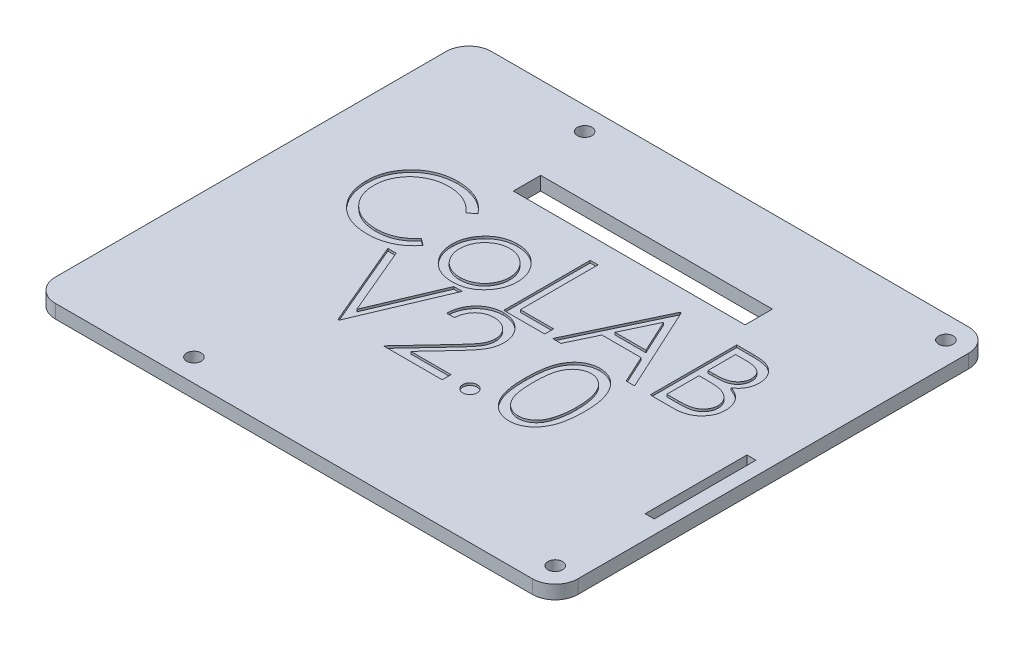
from build123d import *

# Parameters (mm, degrees)
BOSS_EXTRUDE1_DEPTH     = 3
CUT_EXTRUDE1_DEPTH      = 0.5
SKETCH3_R               = 1.6
CUT_EXTRUDE2_DEPTH      = 1
CUT_EXTRUDE2_DEPTH_BACK = 4.0000001
SKETCH5_W               = 2
SKETCH5_H               = 22.4
CUT_EXTRUDE3_DEPTH      = 1.0000001
CUT_EXTRUDE3_DEPTH_BACK = 4
SKETCH6_R               = 3.5
SKETCH6_R_2             = 1.45
BOSS_EXTRUDE2_DEPTH     = 5
SKETCH7_W               = 51
SKETCH7_H               = 6
CUT_EXTRUDE4_DEPTH      = 1.0000001
CUT_EXTRUDE4_DEPTH_BACK = 9


with BuildPart() as part:
    # Sketch1 → Boss-Extrude1 (new body)
    with BuildSketch(Plane(origin=(0, 0, 0), x_dir=(1, 0, 0), z_dir=(0, 1, 0))):
        with BuildLine():
            Line((5, 0), (110, 0))
            ThreePointArc((110, 0), (113.535533906, 1.464466094), (115, 5))
            Line((115, 5), (115, 91))
            ThreePointArc((115, 91), (113.535533906, 94.535533906), (110, 96))
            Line((110, 96), (5, 96))
            ThreePointArc((5, 96), (1.464466094, 94.535533906), (0, 91))
            Line((0, 91), (0, 5))
            ThreePointArc((0, 5), (1.464466094, 1.464466094), (5, 0))
        make_face()
    extrude(amount=BOSS_EXTRUDE1_DEPTH)

    # Sketch2 → Cut-Extrude1 (cut)
    with BuildSketch(Plane(origin=(0, 3, 0), x_dir=(1, 0, 0), z_dir=(0, 1, 0))):
        with BuildLine():
            Line((34.420192308, 63.554447115), (32.924278846, 62.409615385))
            add(Edge.make_bspline(
                [(32.924278846, 62.409615385), (32.817566797, 62.53679302), (32.605581408, 62.789433662), (32.26453632, 63.144196611), (31.909108806, 63.476566105), (31.539434732, 63.788125479), (31.148860096, 64.067979589), (30.74684632, 64.330712307), (30.326668389, 64.566212423), (29.745633947, 64.851760962), (28.985550659, 65.149736463), (28.028724463, 65.399581193), (27.02989977, 65.558627878), (26.348467121, 65.575853658), (26.001862981, 65.584615385)],
                knots=[0, 0, 0, 0, 0.00049794, 0.000989166, 0.001475147, 0.001957397, 0.002438287, 0.002915667, 0.003397525, 0.003882215, 0.004857325, 0.005840349, 0.006844209, 0.007883375, 0.007883375, 0.007883375, 0.007883375], degree=3))
            add(Edge.make_bspline(
                [(26.001862981, 65.584615385), (25.810909594, 65.582416674), (25.430775049, 65.57803966), (24.866631215, 65.520295707), (24.313021608, 65.439136121), (23.770306342, 65.318711147), (23.239176239, 65.166460178), (22.716159022, 64.984530425), (22.208827043, 64.759441939), (21.710162061, 64.51065841), (21.232392355, 64.229657604), (20.780335595, 63.923152074), (20.355640513, 63.594571707), (19.957971152, 63.24268497), (19.586920976, 62.869076586), (19.245178613, 62.469764955), (18.933926594, 62.046026696), (18.646995358, 61.603449435), (18.390023195, 61.143322312), (18.174867709, 60.663942286), (17.984339829, 60.173518525), (17.833576809, 59.666510064), (17.714244796, 59.146484438), (17.631907085, 58.612046007), (17.574819835, 58.064311265), (17.570464586, 57.693057721), (17.568269231, 57.505919471)],
                knots=[0, 0, 0, 0, 0.000572619, 0.001139924, 0.001699592, 0.002250514, 0.002806148, 0.003356514, 0.003910218, 0.00446999, 0.005027612, 0.005571644, 0.006107491, 0.006637367, 0.007163561, 0.007685922, 0.008212558, 0.008739692, 0.009267502, 0.009791769, 0.010314798, 0.010844798, 0.0113771, 0.011914141, 0.012466252, 0.013027427, 0.013027427, 0.013027427, 0.013027427], degree=3))
            add(Edge.make_bspline(
                [(17.568269231, 57.505919471), (17.575137131, 57.224353287), (17.588621343, 56.671535432), (17.708627276, 55.861798252), (17.890990702, 55.086078585), (18.164306913, 54.349225443), (18.50132346, 53.642152809), (18.927175931, 52.976824192), (19.420388799, 52.343185462), (19.987939567, 51.756211704), (20.61063408, 51.220015571), (21.278733428, 50.747844548), (21.990573622, 50.354244974), (22.738294995, 50.026715893), (23.527651415, 49.774947133), (24.357223411, 49.597705261), (25.2252067, 49.482087107), (25.818311576, 49.471018033), (26.12016226, 49.465384615)],
                knots=[0, 0, 0, 0, 0.000844222, 0.001657519, 0.002450727, 0.003230596, 0.004010586, 0.004796148, 0.005595401, 0.006415872, 0.007241219, 0.008057492, 0.008865515, 0.009677279, 0.010502758, 0.011346325, 0.012219621, 0.01312469, 0.01312469, 0.01312469, 0.01312469], degree=3))
            add(Edge.make_bspline(
                [(26.12016226, 49.465384615), (26.452735467, 49.474576402), (27.107319097, 49.492668038), (28.067265069, 49.645934808), (28.986214022, 49.894444332), (29.864215386, 50.242231595), (30.69879396, 50.694344091), (31.491255782, 51.242428252), (32.242269759, 51.891697606), (32.693870595, 52.387450061), (32.924278846, 52.640384615)],
                knots=[0, 0, 0, 0, 0.000997238, 0.001962804, 0.002907981, 0.00384834, 0.004789132, 0.005749229, 0.006733947, 0.007759692, 0.007759692, 0.007759692, 0.007759692], degree=3))
            Line((32.924278846, 52.640384615), (34.420192308, 51.507001202))
            add(Edge.make_bspline(
                [(34.420192308, 51.507001202), (34.299806595, 51.351670485), (34.059611811, 51.041753077), (33.670676033, 50.604845628), (33.260952457, 50.193887949), (32.827397807, 49.812193325), (32.374999542, 49.452124019), (31.895634527, 49.123909766), (31.395604507, 48.822969382), (30.876603701, 48.547414264), (30.339183537, 48.302936105), (29.78398797, 48.093637741), (29.213410123, 47.913343699), (28.627423913, 47.7650153), (28.024813865, 47.64923983), (27.40775457, 47.571844171), (26.774914249, 47.518820322), (26.3479688, 47.513987523), (26.131610577, 47.511538462)],
                knots=[0, 0, 0, 0, 0.000589425, 0.001176026, 0.001753482, 0.00232931, 0.002908013, 0.003487018, 0.004070795, 0.004658029, 0.005248935, 0.005840739, 0.006436956, 0.007043188, 0.007653157, 0.008276538, 0.008908147, 0.009557065, 0.009557065, 0.009557065, 0.009557065], degree=3))
            add(Edge.make_bspline(
                [(26.131610577, 47.511538462), (25.926721475, 47.51296445), (25.521578647, 47.515784164), (24.923415442, 47.561461533), (24.341086438, 47.623780815), (23.776255974, 47.717616386), (23.225841739, 47.828347722), (22.694833415, 47.976781276), (22.17800577, 48.143056026), (21.67743523, 48.338481739), (21.192696006, 48.559005533), (20.725351547, 48.808242446), (20.275616794, 49.084096595), (19.839070146, 49.380487438), (19.422160441, 49.706935324), (19.021274824, 50.058906577), (18.634165346, 50.435214893), (18.394665018, 50.706567737), (18.274248798, 50.842998798)],
                knots=[0, 0, 0, 0, 0.0006145, 0.001215097, 0.001798762, 0.002370923, 0.002932241, 0.003482144, 0.004023991, 0.004560449, 0.005093244, 0.005620764, 0.006148271, 0.006675391, 0.00720287, 0.00773561, 0.008275316, 0.008821059, 0.008821059, 0.008821059, 0.008821059], degree=3))
            add(Edge.make_bspline(
                [(18.274248798, 50.842998798), (18.081377653, 51.079987269), (17.697963872, 51.551103079), (17.207422651, 52.314659634), (16.787519529, 53.111865171), (16.448016303, 53.946907926), (16.182607713, 54.817914134), (15.998741494, 55.725322862), (15.879262047, 56.668286662), (15.865598904, 57.309655469), (15.858653846, 57.635667067)],
                knots=[0, 0, 0, 0, 0.000916064, 0.001821069, 0.002717204, 0.003615773, 0.004521164, 0.005444709, 0.006390426, 0.007368094, 0.007368094, 0.007368094, 0.007368094], degree=3))
            add(Edge.make_bspline(
                [(15.858653846, 57.635667067), (15.867118543, 57.978324607), (15.883772304, 58.652481925), (16.025263705, 59.641851585), (16.252877439, 60.589732771), (16.576166218, 61.494356009), (16.986042487, 62.360479391), (17.492373057, 63.181486521), (18.089275645, 63.962627959), (18.772068835, 64.692051105), (19.520828189, 65.359015296), (20.322663447, 65.945789062), (21.176005187, 66.434108685), (22.071452351, 66.842302083), (23.015710132, 67.156052661), (24.006763899, 67.375689291), (25.04275142, 67.512398167), (25.749574052, 67.52968037), (26.108713942, 67.538461538)],
                knots=[0, 0, 0, 0, 0.001027553, 0.002021647, 0.002991636, 0.003947584, 0.004898354, 0.00586111, 0.006835779, 0.007842891, 0.008853835, 0.009840024, 0.01081793, 0.011798246, 0.012787788, 0.013796915, 0.014839669, 0.015916785, 0.015916785, 0.015916785, 0.015916785], degree=3))
            add(Edge.make_bspline(
                [(26.108713942, 67.538461538), (26.327595568, 67.535837329), (26.760849703, 67.530642971), (27.401760569, 67.479990969), (28.025742377, 67.395552627), (28.633225008, 67.280620875), (29.227163819, 67.137978168), (29.803019415, 66.952157402), (30.36417084, 66.739687138), (30.907079011, 66.494984631), (31.429139091, 66.220301367), (31.930188482, 65.918682045), (32.406247213, 65.590500589), (32.860665088, 65.238548163), (33.285840466, 64.855378861), (33.693845084, 64.451531946), (34.070823238, 64.015374989), (34.303522771, 63.708370992), (34.420192308, 63.554447115)],
                knots=[0, 0, 0, 0, 0.000656548, 0.00129957, 0.001927235, 0.002544702, 0.003153715, 0.00375836, 0.004358654, 0.004953036, 0.005543646, 0.006127422, 0.006706428, 0.007277417, 0.007850392, 0.008422452, 0.008998633, 0.009577991, 0.009577991, 0.009577991, 0.009577991], degree=3))
        make_face()
        with BuildLine():
            add(Edge.make_bspline(
                [(44.563401442, 62.165384615), (44.824611084, 62.159822608), (45.336779356, 62.148916871), (46.086847992, 62.032358272), (46.802829375, 61.854119046), (47.48746565, 61.607712401), (48.131988629, 61.277429213), (48.745786401, 60.883315785), (49.32717612, 60.416413383), (49.675644323, 60.055235897), (49.852524038, 59.871905048)],
                knots=[0, 0, 0, 0, 0.000783055, 0.00153538, 0.002271186, 0.002994326, 0.003712818, 0.004438972, 0.005179778, 0.005943429, 0.005943429, 0.005943429, 0.005943429], degree=3))
            add(Edge.make_bspline(
                [(49.852524038, 59.871905048), (50.004825817, 59.696568925), (50.306481915, 59.349289917), (50.69328247, 58.786195795), (51.026502676, 58.203047533), (51.293545364, 57.59210137), (51.504102421, 56.958690659), (51.653594282, 56.300638284), (51.742513886, 55.619397509), (51.75450432, 55.156733762), (51.760576923, 54.922415865)],
                knots=[0, 0, 0, 0, 0.000696259, 0.001379043, 0.002045498, 0.002708457, 0.003375796, 0.004045107, 0.00473002, 0.005432847, 0.005432847, 0.005432847, 0.005432847], degree=3))
            add(Edge.make_bspline(
                [(51.760576923, 54.922415865), (51.755235644, 54.686739837), (51.744681028, 54.221033014), (51.644839345, 53.535127609), (51.48954872, 52.870038646), (51.267306858, 52.228550613), (50.982329149, 51.608702652), (50.634581264, 51.013202105), (50.221622891, 50.440874065), (49.753515423, 49.896578346), (49.23616164, 49.394930805), (48.674915175, 48.95771551), (48.080805363, 48.583129784), (47.445932254, 48.281397293), (46.776093505, 48.043491639), (46.06984432, 47.876395835), (45.328281865, 47.775367242), (44.821947989, 47.762393793), (44.563401442, 47.755769231)],
                knots=[0, 0, 0, 0, 0.000706639, 0.001396352, 0.002074825, 0.002753062, 0.003429246, 0.004118441, 0.004818465, 0.005543646, 0.006269639, 0.006976516, 0.007674289, 0.008372397, 0.009080888, 0.009802849, 0.01054601, 0.011321441, 0.011321441, 0.011321441, 0.011321441], degree=3))
            add(Edge.make_bspline(
                [(44.563401442, 47.755769231), (44.303588183, 47.762416027), (43.79473079, 47.775434114), (43.050550802, 47.876003324), (42.343035876, 48.04341463), (41.672320219, 48.282179126), (41.034717552, 48.583139428), (40.437165333, 48.956583053), (39.875462935, 49.395060469), (39.357999706, 49.896543212), (38.889921583, 50.440883117), (38.476955637, 51.013199756), (38.129209719, 51.608703264), (37.844231495, 52.228550449), (37.62198977, 52.870038689), (37.466699109, 53.535127597), (37.366857435, 54.221033017), (37.356302818, 54.686739838), (37.350961538, 54.922415865)],
                knots=[0, 0, 0, 0, 0.000779243, 0.001526186, 0.002248147, 0.002956639, 0.00365819, 0.004359201, 0.005066078, 0.005792071, 0.006517252, 0.007217276, 0.007906471, 0.008582655, 0.009260891, 0.009939365, 0.010629078, 0.011335717, 0.011335717, 0.011335717, 0.011335717], degree=3))
            add(Edge.make_bspline(
                [(37.350961538, 54.922415865), (37.357075556, 55.155460208), (37.369180261, 55.616847955), (37.45801046, 56.2968081), (37.606919175, 56.953746746), (37.817728633, 57.584712551), (38.087232743, 58.192981424), (38.41577061, 58.777570576), (38.806516767, 59.338118461), (39.106973103, 59.68494864), (39.259014423, 59.860456731)],
                knots=[0, 0, 0, 0, 0.000699014, 0.001383928, 0.002053239, 0.002716956, 0.003376425, 0.004046203, 0.004725856, 0.005422115, 0.005422115, 0.005422115, 0.005422115], degree=3))
            add(Edge.make_bspline(
                [(39.259014423, 59.860456731), (39.435627469, 60.045377472), (39.782968099, 60.409056647), (40.367251888, 60.874597956), (40.979539686, 61.276912587), (41.631185356, 61.600633131), (42.315259197, 61.855568492), (43.034909645, 62.032817938), (43.787523522, 62.148496913), (44.302198031, 62.159699281), (44.563401442, 62.165384615)],
                knots=[0, 0, 0, 0, 0.000766344, 0.00150715, 0.002235377, 0.002960688, 0.003685145, 0.004420951, 0.005180826, 0.005963881, 0.005963881, 0.005963881, 0.005963881], degree=3))
        make_face()
        with BuildLine():
            add(Edge.make_bspline(
                [(44.555769231, 60.455769231), (44.371051661, 60.450519096), (44.006384975, 60.440154358), (43.469612663, 60.361320534), (42.952866969, 60.236420547), (42.455167517, 60.058961327), (41.978192678, 59.829823034), (41.521485788, 59.548381817), (41.083703508, 59.218365296), (40.673409706, 58.840289898), (40.296860264, 58.427291371), (39.967687277, 57.987245303), (39.68778777, 57.527289333), (39.454614905, 57.046945155), (39.280948638, 56.541345016), (39.154821187, 56.016214723), (39.076061735, 55.470484385), (39.065794446, 55.0994937), (39.060576923, 54.910967548)],
                knots=[0, 0, 0, 0, 0.00055398, 0.001093659, 0.001624001, 0.002146641, 0.00267576, 0.003208513, 0.003753455, 0.004317942, 0.004879857, 0.00542785, 0.00596386, 0.006492979, 0.007026416, 0.007564175, 0.008111411, 0.008676826, 0.008676826, 0.008676826, 0.008676826], degree=3))
            add(Edge.make_bspline(
                [(39.060576923, 54.910967548), (39.069322635, 54.667388657), (39.086681237, 54.183930107), (39.227843023, 53.471943854), (39.463988347, 52.788419773), (39.782870541, 52.137364872), (40.182410102, 51.534991473), (40.653146851, 50.99793668), (41.190028649, 50.534282477), (41.7866556, 50.149576732), (42.430841244, 49.843907205), (43.112593506, 49.627287066), (43.823652141, 49.48647114), (44.309594406, 49.472474972), (44.555769231, 49.465384615)],
                knots=[0, 0, 0, 0, 0.000730313, 0.001449535, 0.002167582, 0.002894618, 0.003618562, 0.004329721, 0.005030483, 0.005739673, 0.006453204, 0.007162815, 0.007881317, 0.008619021, 0.008619021, 0.008619021, 0.008619021], degree=3))
            add(Edge.make_bspline(
                [(44.555769231, 49.465384615), (44.801929896, 49.472516284), (45.287844211, 49.486593999), (45.997914874, 49.62657786), (46.677803778, 49.844856357), (47.32132033, 50.149232956), (47.9176757, 50.535743385), (48.458418775, 50.995318523), (48.925136215, 51.536413914), (49.32428055, 52.138162749), (49.648384964, 52.787410437), (49.883424963, 53.472070008), (50.024926109, 54.183897979), (50.042238905, 54.667377893), (50.050961538, 54.910967548)],
                knots=[0, 0, 0, 0, 0.000737704, 0.001456207, 0.002162186, 0.002875716, 0.003584906, 0.004288562, 0.004997207, 0.005721152, 0.006449878, 0.007167925, 0.007887147, 0.00861746, 0.00861746, 0.00861746, 0.00861746], degree=3))
            add(Edge.make_bspline(
                [(50.050961538, 54.910967548), (50.045745812, 55.099494826), (50.035482057, 55.470487729), (49.956696894, 56.016201941), (49.8306646, 56.541391917), (49.656647654, 57.046772106), (49.42448795, 57.528533022), (49.139190834, 57.985894822), (48.811361967, 58.428815737), (48.43026878, 58.838954839), (48.020403252, 59.218512681), (47.582443544, 59.548509786), (47.126413875, 59.828586128), (46.650824732, 60.060921237), (46.153061471, 60.234806047), (45.637039811, 60.362041712), (45.102557717, 60.439821211), (44.739197782, 60.450419224), (44.555769231, 60.455769231)],
                knots=[0, 0, 0, 0, 0.000565415, 0.00111265, 0.00165041, 0.002183846, 0.002712966, 0.003250969, 0.003798962, 0.004363449, 0.004927936, 0.005472878, 0.006005632, 0.006531314, 0.007057549, 0.007584185, 0.008123864, 0.008674032, 0.008674032, 0.008674032, 0.008674032], degree=3))
        make_face(mode=Mode.SUBTRACT)
        Polygon((55.668269231, 67.05), (57.377884615, 67.05), (57.377884615, 49.953846154), (64.704807692, 49.953846154), (64.704807692, 48), (55.668269231, 48), align=None)
        Polygon((75.695192308, 67.05), (84.4875, 48), (82.62905649, 48), (79.812770433, 54.105769231), (71.176923077, 54.105769231), (68.280498798, 48), (66.414423077, 48), (75.450961538, 67.05), align=None)
        Polygon((75.553996394, 63.336929087), (72.104236779, 56.059615385), (78.912169471, 56.059615385), align=None, mode=Mode.SUBTRACT)
        with BuildLine():
            Line((87.906730769, 67.05), (91.623617788, 67.05))
            add(Edge.make_bspline(
                [(91.623617788, 67.05), (91.80556422, 67.049043416), (92.158221686, 67.047189317), (92.671044648, 67.018433989), (93.151370317, 66.979225443), (93.599337993, 66.917013082), (94.014740673, 66.841946409), (94.398830241, 66.75104081), (94.750385322, 66.642038813), (95.17009893, 66.468704053), (95.648638527, 66.211130809), (96.166789778, 65.830519618), (96.609861424, 65.36497864), (96.991875522, 64.83983733), (97.295593045, 64.262155487), (97.515317363, 63.645701902), (97.654425227, 62.99842785), (97.668731419, 62.554055696), (97.675961538, 62.329477163)],
                knots=[0, 0, 0, 0, 0.000545756, 0.001057812, 0.00154047, 0.00199111, 0.00241401, 0.002806457, 0.003174568, 0.003516849, 0.004167392, 0.004800106, 0.005437019, 0.006087371, 0.006742853, 0.007387425, 0.008046032, 0.008718977, 0.008718977, 0.008718977, 0.008718977], degree=3))
            add(Edge.make_bspline(
                [(97.675961538, 62.329477163), (97.670011307, 62.119096825), (97.65831854, 61.705679619), (97.546507236, 61.101010253), (97.371461312, 60.525421476), (97.128137027, 59.981013921), (96.811896162, 59.480088113), (96.43711017, 59.018603136), (95.984935003, 58.616098097), (95.646153939, 58.391074585), (95.47406851, 58.276772837)],
                knots=[0, 0, 0, 0, 0.000630593, 0.001239176, 0.001837903, 0.002432285, 0.003022056, 0.003610343, 0.004210261, 0.004829576, 0.004829576, 0.004829576, 0.004829576], degree=3))
            add(Edge.make_bspline(
                [(95.47406851, 58.276772837), (95.690478837, 58.193687628), (96.104525402, 58.034725042), (96.674316412, 57.753680588), (97.165234069, 57.447998245), (97.581052821, 57.114177746), (97.936676342, 56.754356933), (98.247207353, 56.363259811), (98.512173118, 55.935784572), (98.739210602, 55.476388187), (98.916368831, 54.989761552), (99.049043396, 54.480469185), (99.125066227, 53.95033732), (99.135884674, 53.589555469), (99.141346154, 53.407421875)],
                knots=[0, 0, 0, 0, 0.00069517, 0.001330033, 0.001902818, 0.002426682, 0.002925892, 0.003417578, 0.003921593, 0.004431882, 0.004952231, 0.005472399, 0.0060083, 0.006554657, 0.006554657, 0.006554657, 0.006554657], degree=3))
            add(Edge.make_bspline(
                [(99.141346154, 53.407421875), (99.13602932, 53.221456471), (99.125568302, 52.855564329), (99.048388741, 52.318054239), (98.917710602, 51.804384887), (98.737709076, 51.311233821), (98.502782764, 50.839555089), (98.216880558, 50.388814324), (97.875985905, 49.963540324), (97.494643718, 49.559007461), (97.063231183, 49.195273362), (96.597781146, 48.871337873), (96.09243189, 48.604931449), (95.55548318, 48.381142817), (94.980911688, 48.210197923), (94.371297497, 48.090604342), (93.727166368, 48.010022641), (93.285153294, 48.003397568), (93.058473558, 48)],
                knots=[0, 0, 0, 0, 0.000557791, 0.00109747, 0.001625032, 0.002145382, 0.002669315, 0.003202874, 0.00374343, 0.00430216, 0.004867987, 0.005433235, 0.006000039, 0.006578327, 0.007175946, 0.007794874, 0.008440506, 0.009120159, 0.009120159, 0.009120159, 0.009120159], degree=3))
            Line((93.058473558, 48), (87.906730769, 48))
            Line((87.906730769, 48), (87.906730769, 67.05))
        make_face()
        with BuildLine():
            Line((89.616346154, 65.096153846), (89.616346154, 58.990384615))
            Line((89.616346154, 58.990384615), (90.76499399, 58.990384615))
            add(Edge.make_bspline(
                [(90.76499399, 58.990384615), (90.932899577, 58.992561339), (91.257327386, 58.996767213), (91.727154252, 59.00881507), (92.163263279, 59.042550135), (92.564901685, 59.076275504), (92.931436987, 59.131110046), (93.262057148, 59.196381458), (93.56195094, 59.265412698), (93.907787609, 59.382812334), (94.300070371, 59.556317966), (94.718261981, 59.825586103), (95.086931023, 60.146302939), (95.398247144, 60.516368031), (95.653035291, 60.923853986), (95.830002798, 61.362259149), (95.950003016, 61.820657296), (95.960842637, 62.135353787), (95.966346154, 62.295132212)],
                knots=[0, 0, 0, 0, 0.000503784, 0.000973413, 0.001409519, 0.001815822, 0.002182268, 0.002520548, 0.002826908, 0.003104462, 0.003615151, 0.004109495, 0.004590899, 0.005075605, 0.005555358, 0.006025916, 0.006489616, 0.006967864, 0.006967864, 0.006967864, 0.006967864], degree=3))
            add(Edge.make_bspline(
                [(95.966346154, 62.295132212), (95.96348223, 62.400863911), (95.957864331, 62.608268185), (95.911854213, 62.910615384), (95.833653558, 63.194970665), (95.733209476, 63.465230894), (95.592845327, 63.712945393), (95.427581334, 63.946679073), (95.227906363, 64.158472175), (95.000627275, 64.356426159), (94.7393232, 64.531928517), (94.444150026, 64.685638957), (94.11111424, 64.809413755), (93.745828558, 64.917814528), (93.342670211, 64.993950813), (92.90629157, 65.057378537), (92.433118314, 65.089669604), (92.105757113, 65.093944222), (91.936538462, 65.096153846)],
                knots=[0, 0, 0, 0, 0.000317104, 0.000622035, 0.000914559, 0.001200868, 0.001484418, 0.001766113, 0.002057739, 0.002355347, 0.002668639, 0.002999762, 0.003351279, 0.00373289, 0.004141516, 0.004580816, 0.005055258, 0.005562929, 0.005562929, 0.005562929, 0.005562929], degree=3))
            Line((91.936538462, 65.096153846), (89.616346154, 65.096153846))
        make_face(mode=Mode.SUBTRACT)
        with BuildLine():
            Line((89.616346154, 57.036538462), (89.616346154, 49.953846154))
            Line((89.616346154, 49.953846154), (92.051021635, 49.953846154))
            add(Edge.make_bspline(
                [(92.051021635, 49.953846154), (92.225296074, 49.955934836), (92.561187082, 49.959960496), (93.046152348, 49.973102571), (93.495640385, 50.002996243), (93.907600095, 50.050054368), (94.286479844, 50.101099927), (94.627734485, 50.169741327), (94.934130295, 50.248384955), (95.289409027, 50.369946664), (95.689478122, 50.558794599), (96.120611498, 50.84353346), (96.503931342, 51.182750321), (96.829442825, 51.575348582), (97.096213519, 52.00223909), (97.290281068, 52.454787352), (97.409974159, 52.925515723), (97.424463967, 53.246463115), (97.431730769, 53.407421875)],
                knots=[0, 0, 0, 0, 0.000522862, 0.001007748, 0.001455275, 0.001873744, 0.002251519, 0.00260177, 0.002917401, 0.003199793, 0.003727272, 0.004239541, 0.004745013, 0.005257068, 0.005764323, 0.006249869, 0.006729304, 0.007211645, 0.007211645, 0.007211645, 0.007211645], degree=3))
            add(Edge.make_bspline(
                [(97.431730769, 53.407421875), (97.430227973, 53.508078486), (97.42724662, 53.707768106), (97.382285273, 54.001224208), (97.316895496, 54.285482176), (97.23236012, 54.561313877), (97.109245592, 54.823732397), (96.96551854, 55.077927757), (96.797000054, 55.324235981), (96.534413951, 55.635634103), (96.152477864, 55.994410988), (95.609788129, 56.345679393), (94.992718907, 56.628968171), (94.54516641, 56.749252464), (94.313972356, 56.811388221)],
                knots=[0, 0, 0, 0, 0.00030169, 0.000598513, 0.000888261, 0.001176699, 0.001461887, 0.001755827, 0.002052208, 0.00235563, 0.002976636, 0.003615922, 0.004287047, 0.005004191, 0.005004191, 0.005004191, 0.005004191], degree=3))
            add(Edge.make_bspline(
                [(94.313972356, 56.811388221), (94.22128542, 56.83019375), (94.020321024, 56.870968014), (93.692619765, 56.914008514), (93.31850025, 56.952353768), (92.89709859, 56.980717355), (92.427881626, 57.010035542), (91.909847254, 57.021437354), (91.345111013, 57.03504047), (90.953266815, 57.036026358), (90.749729567, 57.036538462)],
                knots=[0, 0, 0, 0, 0.000283652, 0.000615017, 0.000990937, 0.001411818, 0.001881958, 0.002401173, 0.002966073, 0.003576662, 0.003576662, 0.003576662, 0.003576662], degree=3))
            Line((90.749729567, 57.036538462), (89.616346154, 57.036538462))
        make_face(mode=Mode.SUBTRACT)
        Polygon((31.123076923, 47.05), (32.954807692, 47.05), (39.304807692, 32.037439904), (45.654807692, 47.05), (47.486538462, 47.05), (39.426923077, 28), (39.182692308, 28), align=None)
        with BuildLine():
            Line((51.638461538, 41.188461538), (49.928846154, 41.188461538))
            add(Edge.make_bspline(
                [(49.928846154, 41.188461538), (49.939988515, 41.415270228), (49.961871816, 41.860716457), (50.064351505, 42.510179433), (50.210986851, 43.130963409), (50.418313194, 43.718083941), (50.675794505, 44.276732306), (50.98456794, 44.804689534), (51.350294469, 45.299941576), (51.765076836, 45.75789728), (52.215574714, 46.178018201), (52.701654185, 46.540813165), (53.212439262, 46.847342205), (53.746380276, 47.103598679), (54.309501344, 47.295948411), (54.896692327, 47.43866905), (55.510533055, 47.524537446), (55.928762318, 47.533767365), (56.141466346, 47.538461538)],
                knots=[0, 0, 0, 0, 0.000680809, 0.00133709, 0.001969252, 0.002592014, 0.003201565, 0.003812201, 0.004423565, 0.00504504, 0.005663449, 0.006268684, 0.006860967, 0.007448164, 0.008041934, 0.008642628, 0.00925895, 0.009896799, 0.009896799, 0.009896799, 0.009896799], degree=3))
            add(Edge.make_bspline(
                [(56.141466346, 47.538461538), (56.350352721, 47.533571368), (56.760806985, 47.523962359), (57.359858807, 47.441443042), (57.930146652, 47.312199179), (58.470555782, 47.130868128), (58.976774505, 46.887112887), (59.452605647, 46.59430057), (59.90371406, 46.255646916), (60.309788125, 45.856936874), (60.682667814, 45.431292467), (61.004352945, 44.976879735), (61.279833163, 44.507546051), (61.509454678, 44.019712554), (61.678488806, 43.508785956), (61.806821624, 42.982204753), (61.879360833, 42.434518281), (61.890493781, 42.063824029), (61.896153846, 41.875360577)],
                knots=[0, 0, 0, 0, 0.000626411, 0.001230876, 0.001810371, 0.002378766, 0.002936923, 0.003491927, 0.004052907, 0.004625069, 0.005195867, 0.00574861, 0.006292495, 0.006826886, 0.007362692, 0.007904163, 0.008450879, 0.009016294, 0.009016294, 0.009016294, 0.009016294], degree=3))
            add(Edge.make_bspline(
                [(61.896153846, 41.875360577), (61.886937658, 41.610033077), (61.868667014, 41.0840342), (61.712378764, 40.31106759), (61.468285611, 39.562166266), (61.174385711, 38.95943895), (60.87789998, 38.473753792), (60.610723689, 38.073874126), (60.297950932, 37.643314363), (59.935029393, 37.183516283), (59.529466474, 36.690878357), (59.0775887, 36.165698185), (58.576173747, 35.613401838), (58.224246765, 35.23618135), (58.041887019, 35.040715144)],
                knots=[0, 0, 0, 0, 0.000795299, 0.001576641, 0.002356211, 0.003153266, 0.003581282, 0.004062853, 0.004595648, 0.00517735, 0.005819874, 0.006509872, 0.007255587, 0.008057559, 0.008057559, 0.008057559, 0.008057559], degree=3))
            Line((58.041887019, 35.040715144), (53.275570913, 29.953846154))
            Line((53.275570913, 29.953846154), (62.140384615, 29.953846154))
            Line((62.140384615, 29.953846154), (62.140384615, 28))
            Line((62.140384615, 28), (49.196153846, 28))
            Line((49.196153846, 28), (56.584134615, 35.884074519))
            add(Edge.make_bspline(
                [(56.584134615, 35.884074519), (56.764009542, 36.071843873), (57.109512464, 36.432510375), (57.598186204, 36.959068486), (58.037092697, 37.447562415), (58.429073078, 37.8970692), (58.765624014, 38.314163877), (59.064285734, 38.685337906), (59.303584165, 39.026901414), (59.563292247, 39.422818184), (59.814828346, 39.906210939), (60.030977026, 40.496944305), (60.162774987, 41.10505978), (60.178585592, 41.516006582), (60.186538462, 41.722716346)],
                knots=[0, 0, 0, 0, 0.000780065, 0.001498345, 0.002154992, 0.002750207, 0.003287207, 0.003762814, 0.004178927, 0.004537763, 0.005182945, 0.005808274, 0.006420494, 0.007040127, 0.007040127, 0.007040127, 0.007040127], degree=3))
            add(Edge.make_bspline(
                [(60.186538462, 41.722716346), (60.183078207, 41.852699386), (60.17625871, 42.108870997), (60.116073242, 42.484459486), (60.025120345, 42.846762258), (59.894789726, 43.196893742), (59.722758755, 43.531333648), (59.513353644, 43.850489076), (59.27174487, 44.159039015), (58.992247247, 44.448344823), (58.685207404, 44.71330967), (58.360844417, 44.948027907), (58.017671706, 45.144183638), (57.657136184, 45.304984673), (57.280242986, 45.431124962), (56.886263159, 45.518529516), (56.476285299, 45.573407036), (56.19634013, 45.580832028), (56.053695913, 45.584615385)],
                knots=[0, 0, 0, 0, 0.00038971, 0.000768044, 0.001138265, 0.001508978, 0.001886155, 0.002264027, 0.002652614, 0.003060152, 0.003468689, 0.003867942, 0.004259386, 0.004652278, 0.005050509, 0.005449524, 0.005861328, 0.006289158, 0.006289158, 0.006289158, 0.006289158], degree=3))
            add(Edge.make_bspline(
                [(56.053695913, 45.584615385), (55.904720381, 45.580723566), (55.612157033, 45.573080677), (55.182612011, 45.51961732), (54.772842279, 45.427383532), (54.381817064, 45.301236204), (54.008874747, 45.140897531), (53.655829022, 44.941189607), (53.323472439, 44.702882308), (53.011180219, 44.432695852), (52.723449133, 44.131882194), (52.470645423, 43.796547966), (52.249752431, 43.432815891), (52.057025032, 43.041667409), (51.900511919, 42.619553263), (51.7809152, 42.167971898), (51.686281077, 41.688884094), (51.654666129, 41.35803956), (51.638461538, 41.188461538)],
                knots=[0, 0, 0, 0, 0.000446892, 0.000877622, 0.001296091, 0.001705198, 0.002108569, 0.002511851, 0.002919531, 0.003333451, 0.003749144, 0.004165869, 0.004590624, 0.005024118, 0.0054721, 0.005938665, 0.006424391, 0.006935151, 0.006935151, 0.006935151, 0.006935151], degree=3))
        make_face()
        with BuildLine():
            add(Edge.make_bspline(
                [(66.902884615, 30.930769231), (67.008967056, 30.924465495), (67.216929279, 30.912107758), (67.517587963, 30.827326148), (67.789701754, 30.67678401), (68.0320844, 30.476145174), (68.231872508, 30.232873064), (68.387779625, 29.962929618), (68.471822701, 29.659753807), (68.484090421, 29.450586576), (68.490384615, 29.343269231)],
                knots=[0, 0, 0, 0, 0.000318205, 0.000623803, 0.000927753, 0.001244857, 0.001561962, 0.001867751, 0.002173349, 0.002495352, 0.002495352, 0.002495352, 0.002495352], degree=3))
            add(Edge.make_bspline(
                [(68.490384615, 29.343269231), (68.483877131, 29.238530536), (68.471044468, 29.031987368), (68.387972273, 28.731098264), (68.230684314, 28.460986113), (68.033462424, 28.214413047), (67.789641835, 28.013349165), (67.516944642, 27.864087817), (67.21763508, 27.773235755), (67.009084806, 27.761662624), (66.902884615, 27.755769231)],
                knots=[0, 0, 0, 0, 0.000314406, 0.000620005, 0.000925794, 0.001245846, 0.001562951, 0.001866901, 0.002173569, 0.002491774, 0.002491774, 0.002491774, 0.002491774], degree=3))
            add(Edge.make_bspline(
                [(66.902884615, 27.755769231), (66.7966079, 27.761449381), (66.589127914, 27.772538522), (66.290935573, 27.865953225), (66.016577645, 28.011949487), (65.772804528, 28.214787952), (65.573930847, 28.459717304), (65.423569834, 28.73295851), (65.333272024, 29.031126048), (65.321396402, 29.23836089), (65.315384615, 29.343269231)],
                knots=[0, 0, 0, 0, 0.000318205, 0.000621219, 0.000928528, 0.001245632, 0.001565685, 0.001869635, 0.002176304, 0.00249071, 0.00249071, 0.00249071, 0.00249071], degree=3))
            add(Edge.make_bspline(
                [(65.315384615, 29.343269231), (65.32116547, 29.450762283), (65.332451879, 29.660629275), (65.423759401, 29.961070131), (65.572764212, 30.234129779), (65.77417929, 30.475774022), (66.016518672, 30.678179198), (66.290273732, 30.825489001), (66.589846087, 30.912794673), (66.796728751, 30.9246738), (66.902884615, 30.930769231)],
                knots=[0, 0, 0, 0, 0.000322003, 0.000628672, 0.000932622, 0.001249726, 0.001566831, 0.00187414, 0.002176071, 0.002494275, 0.002494275, 0.002494275, 0.002494275], degree=3))
        make_face()
        with BuildLine():
            add(Edge.make_bspline(
                [(70.932692308, 37.517367788), (70.934477664, 37.822697856), (70.937945743, 38.415805913), (70.976527006, 39.280048036), (71.040618512, 40.090817609), (71.128451927, 40.84815344), (71.235338648, 41.552251044), (71.378025796, 42.201228794), (71.540292622, 42.798090367), (71.728356649, 43.344782088), (71.940561615, 43.8486693), (72.171525234, 44.319069324), (72.430413615, 44.755270413), (72.702430812, 45.164234672), (72.998587945, 45.53926764), (73.310457076, 45.88566556), (73.650210431, 46.195422645), (74.006298519, 46.477614662), (74.381945275, 46.724989644), (74.766443215, 46.942882121), (75.162438863, 47.129027113), (75.571013372, 47.275387914), (75.988494438, 47.39627838), (76.416341472, 47.478949652), (76.855260896, 47.530966539), (77.151523419, 47.535939502), (77.301772837, 47.538461538)],
                knots=[0, 0, 0, 0, 0.000915937, 0.001779221, 0.002594636, 0.003355306, 0.004066137, 0.004730062, 0.005347576, 0.005920818, 0.006463001, 0.006986934, 0.007491541, 0.0079837, 0.008459307, 0.008923933, 0.009380352, 0.009836884, 0.010285645, 0.010728215, 0.01116186, 0.01159646, 0.012028911, 0.012464482, 0.012902338, 0.013352897, 0.013352897, 0.013352897, 0.013352897], degree=3))
            add(Edge.make_bspline(
                [(77.301772837, 47.538461538), (77.453277369, 47.53580643), (77.754572218, 47.530526255), (78.200017689, 47.479777368), (78.635172385, 47.395570255), (79.058181111, 47.276257522), (79.472518538, 47.128235339), (79.874943842, 46.94270403), (80.267956672, 46.726737624), (80.645311523, 46.47297052), (81.011151072, 46.190038417), (81.356489271, 45.870201605), (81.681357552, 45.516689562), (81.989833143, 45.13328456), (82.273164322, 44.712632884), (82.542985432, 44.2620508), (82.784496085, 43.773658522), (83.017094817, 43.255604832), (83.217865416, 42.69355549), (83.398928837, 42.090678722), (83.545227223, 41.439853505), (83.667088833, 40.744494512), (83.761494624, 40.002048068), (83.83025229, 39.214105693), (83.866572939, 38.380148996), (83.873412984, 37.809966988), (83.876923077, 37.517367788)],
                knots=[0, 0, 0, 0, 0.000454373, 0.000903605, 0.001342922, 0.001782718, 0.002220906, 0.002661481, 0.003110713, 0.003564765, 0.004024301, 0.004496898, 0.004974887, 0.005463587, 0.005971645, 0.006495217, 0.007037923, 0.007605177, 0.008197903, 0.008826959, 0.009492549, 0.010197734, 0.01094418, 0.011737095, 0.012569881, 0.013447718, 0.013447718, 0.013447718, 0.013447718], degree=3))
            add(Edge.make_bspline(
                [(83.876923077, 37.517367788), (83.873376595, 37.226044804), (83.866466421, 36.658413849), (83.830659459, 35.82820954), (83.760127481, 35.044448762), (83.671898831, 34.305251816), (83.549701446, 33.613695348), (83.39945047, 32.967386278), (83.232625142, 32.363533545), (83.026695762, 31.807084071), (82.801303182, 31.290275408), (82.556074185, 30.807672786), (82.293348418, 30.355010536), (82.007115391, 29.935911913), (81.702024671, 29.54740808), (81.37154642, 29.196356734), (81.024996521, 28.874299219), (80.658080372, 28.587723933), (80.274840358, 28.336890924), (79.883177382, 28.112569824), (79.47614211, 27.931689013), (79.062958753, 27.776376861), (78.637717217, 27.657720116), (78.200947576, 27.575675274), (77.754871492, 27.518134213), (77.453328688, 27.513744658), (77.301772837, 27.511538462)],
                knots=[0, 0, 0, 0, 0.000874022, 0.001702995, 0.002492108, 0.003234289, 0.003935716, 0.004597588, 0.00522451, 0.005813651, 0.006375876, 0.006915177, 0.007436812, 0.00794487, 0.008436556, 0.008917143, 0.00938974, 0.009854632, 0.010311864, 0.010762956, 0.011207004, 0.011646503, 0.0120863, 0.012529363, 0.012979032, 0.013433405, 0.013433405, 0.013433405, 0.013433405], degree=3))
            add(Edge.make_bspline(
                [(77.301772837, 27.511538462), (77.151527588, 27.514076768), (76.855273283, 27.519081812), (76.416293653, 27.570863693), (75.990213496, 27.654114932), (75.574930278, 27.770682449), (75.168313389, 27.913366058), (74.7759036, 28.099259679), (74.393337779, 28.313349397), (74.021636595, 28.557164476), (73.66778469, 28.836501066), (73.329790853, 29.14546098), (73.016146106, 29.491754119), (72.724223385, 29.869912529), (72.446778705, 30.276457176), (72.191566545, 30.71693875), (71.955505182, 31.189610672), (71.739731326, 31.697526729), (71.548422171, 32.248098551), (71.379433932, 32.847624794), (71.246006875, 33.501397042), (71.131799646, 34.204164426), (71.039682647, 34.958946818), (70.976794105, 35.766153982), (70.937924947, 36.625282905), (70.93446835, 37.21457982), (70.932692308, 37.517367788)],
                knots=[0, 0, 0, 0, 0.000450559, 0.000888415, 0.001323986, 0.00175173, 0.002181445, 0.00261509, 0.003052463, 0.003495936, 0.003947109, 0.004403529, 0.004868154, 0.005346767, 0.005835765, 0.006343666, 0.006872716, 0.007419899, 0.007997998, 0.00862021, 0.009287069, 0.009998504, 0.010755835, 0.011567446, 0.012426918, 0.013335223, 0.013335223, 0.013335223, 0.013335223], degree=3))
        make_face()
        with BuildLine():
            add(Edge.make_bspline(
                [(72.642307692, 37.525), (72.642957826, 37.270553511), (72.644219607, 36.776722838), (72.677182641, 36.059118804), (72.722087475, 35.389808871), (72.780006536, 34.767943194), (72.866019727, 34.195626697), (72.962395244, 33.668923137), (73.079678417, 33.190619889), (73.218444157, 32.757434805), (73.376499813, 32.362016304), (73.5490703, 31.994072547), (73.734457949, 31.649257007), (73.94193504, 31.330666939), (74.167895598, 31.037263389), (74.407235766, 30.763853258), (74.668887974, 30.520029689), (75.030858344, 30.227602092), (75.508722012, 29.925419378), (76.110813347, 29.662278518), (76.729494487, 29.496911148), (77.14941772, 29.475881276), (77.359014423, 29.465384615)],
                knots=[0, 0, 0, 0, 0.000763259, 0.001481336, 0.00215453, 0.002775747, 0.003354287, 0.003890175, 0.004381638, 0.004830579, 0.005253633, 0.00565823, 0.006049283, 0.006427155, 0.006797337, 0.007159566, 0.007515917, 0.007868737, 0.008554787, 0.009204198, 0.009834503, 0.01046262, 0.01046262, 0.01046262, 0.01046262], degree=3))
            add(Edge.make_bspline(
                [(77.359014423, 29.465384615), (77.569966893, 29.474081108), (77.991436295, 29.491456138), (78.60720738, 29.659089266), (79.20499785, 29.912016331), (79.673475125, 30.211087753), (80.029887255, 30.495903375), (80.285249729, 30.738734532), (80.519630307, 31.010637182), (80.741927886, 31.304003349), (80.945812284, 31.62443787), (81.131213076, 31.970399887), (81.300395296, 32.342850127), (81.396783103, 32.602853993), (81.446063702, 32.73578726)],
                knots=[0, 0, 0, 0, 0.000631609, 0.001261913, 0.001901291, 0.002573586, 0.00292104, 0.003269227, 0.003628935, 0.003996808, 0.004372612, 0.004767021, 0.005173485, 0.005598703, 0.005598703, 0.005598703, 0.005598703], degree=3))
            add(Edge.make_bspline(
                [(81.446063702, 32.73578726), (81.503495467, 32.90576627), (81.620106579, 33.250896558), (81.770393522, 33.786275865), (81.888750623, 34.347993766), (81.995231228, 34.932693329), (82.067910004, 35.544686559), (82.126408816, 36.182079877), (82.160865841, 36.845353863), (82.165137129, 37.295995172), (82.167307692, 37.525)],
                knots=[0, 0, 0, 0, 0.00053822, 0.001092817, 0.001666922, 0.002259808, 0.002875136, 0.003514992, 0.004179882, 0.004866876, 0.004866876, 0.004866876, 0.004866876], degree=3))
            add(Edge.make_bspline(
                [(82.167307692, 37.525), (82.164313091, 37.753967788), (82.15845501, 38.201877727), (82.136063163, 38.857840968), (82.078240565, 39.480872638), (82.014019646, 40.073656782), (81.919329057, 40.632912001), (81.817232994, 41.163320091), (81.680066396, 41.658309983), (81.533545906, 42.125631421), (81.365849325, 42.559974983), (81.181250828, 42.963365735), (80.98410097, 43.337751165), (80.769966776, 43.68210409), (80.541390272, 43.997966931), (80.292338468, 44.279006652), (80.032690382, 44.533933579), (79.669013985, 44.824922705), (79.192903922, 45.121622076), (78.600472613, 45.394667141), (77.983956678, 45.551466562), (77.567178306, 45.573573744), (77.359014423, 45.584615385)],
                knots=[0, 0, 0, 0, 0.000686994, 0.001343908, 0.001968223, 0.002563695, 0.00313209, 0.003669443, 0.004183202, 0.004671976, 0.005138291, 0.005578866, 0.00600223, 0.006406737, 0.00679448, 0.007170343, 0.007531968, 0.007884787, 0.008565575, 0.009209547, 0.009835214, 0.01045953, 0.01045953, 0.01045953, 0.01045953], degree=3))
            add(Edge.make_bspline(
                [(77.359014423, 45.584615385), (77.1483182, 45.573558511), (76.726541917, 45.55142462), (76.103618049, 45.39525134), (75.506512935, 45.123037911), (75.031661887, 44.823939998), (74.667731849, 44.539070046), (74.411467475, 44.29203806), (74.171186167, 44.02182059), (73.949837684, 43.725718739), (73.742523157, 43.407500097), (73.552126503, 43.064661249), (73.38058218, 42.695464823), (73.222279205, 42.300223939), (73.083090173, 41.867076227), (72.968278744, 41.389362134), (72.862213498, 40.864333837), (72.78712782, 40.288917658), (72.72037795, 39.666896223), (72.677480899, 38.995915391), (72.64410934, 38.277107835), (72.64292027, 37.780723844), (72.642307692, 37.525)],
                knots=[0, 0, 0, 0, 0.00063192, 0.001264991, 0.001912448, 0.002593236, 0.002943674, 0.003297256, 0.003659485, 0.004027358, 0.00440523, 0.004798122, 0.005202719, 0.005625774, 0.006074714, 0.006566177, 0.00709904, 0.007680818, 0.008306217, 0.008975604, 0.009697493, 0.010464569, 0.010464569, 0.010464569, 0.010464569], degree=3))
        make_face(mode=Mode.SUBTRACT)
    extrude(amount=-CUT_EXTRUDE1_DEPTH, mode=Mode.SUBTRACT)

    # Sketch3 → Cut-Extrude2 (cut, two sides)
    with BuildSketch(Plane.XZ) as cut_extrude2_sk:
        with Locations((30.5, -91)):
            Circle(SKETCH3_R)
        with Locations((110, -91)):
            Circle(SKETCH3_R)
        with Locations((110, -5)):
            Circle(SKETCH3_R)
        with Locations((30.5, -5)):
            Circle(SKETCH3_R)
    extrude(amount=CUT_EXTRUDE2_DEPTH, mode=Mode.SUBTRACT)
    extrude(cut_extrude2_sk.sketch, amount=-CUT_EXTRUDE2_DEPTH_BACK, mode=Mode.SUBTRACT)

    # Sketch5 → Cut-Extrude3 (cut, two sides)
    with BuildSketch(Plane(origin=(0, 3, 0), x_dir=(1, 0, 0), z_dir=(0, 1, 0))) as cut_extrude3_sk:
        with Locations((111, 36)):
            Rectangle(SKETCH5_W, SKETCH5_H)
    extrude(amount=CUT_EXTRUDE3_DEPTH, mode=Mode.SUBTRACT)
    extrude(cut_extrude3_sk.sketch, amount=-CUT_EXTRUDE3_DEPTH_BACK, mode=Mode.SUBTRACT)

    # Sketch6 → Boss-Extrude2 (add)
    with BuildSketch(Plane.XZ):
        with Locations((12.34, -37.36)):
            Circle(SKETCH6_R)
        with Locations((12.34, -37.36)):
            Circle(SKETCH6_R_2, mode=Mode.SUBTRACT)
        with Locations((31.14, -20.6)):
            Circle(SKETCH6_R)
        with Locations((31.14, -20.6)):
            Circle(SKETCH6_R_2, mode=Mode.SUBTRACT)
        with Locations((80, -23)):
            Circle(SKETCH6_R)
        with Locations((80, -23)):
            Circle(SKETCH6_R_2, mode=Mode.SUBTRACT)
        with Locations((55, -58.7)):
            Circle(SKETCH6_R)
        with Locations((55, -58.7)):
            Circle(SKETCH6_R_2, mode=Mode.SUBTRACT)
        with Locations((92, -60)):
            Circle(SKETCH6_R)
        with Locations((92, -60)):
            Circle(SKETCH6_R_2, mode=Mode.SUBTRACT)
    extrude(amount=BOSS_EXTRUDE2_DEPTH)

    # Sketch7 → Cut-Extrude4 (cut, two sides)
    with BuildSketch(Plane(origin=(0, 3, 0), x_dir=(1, 0, 0), z_dir=(0, 1, 0))) as cut_extrude4_sk:
        with Locations((59.5, 74.8)):
            Rectangle(SKETCH7_W, SKETCH7_H)
    extrude(amount=CUT_EXTRUDE4_DEPTH, mode=Mode.SUBTRACT)
    extrude(cut_extrude4_sk.sketch, amount=-CUT_EXTRUDE4_DEPTH_BACK, mode=Mode.SUBTRACT)


solid = part.part
